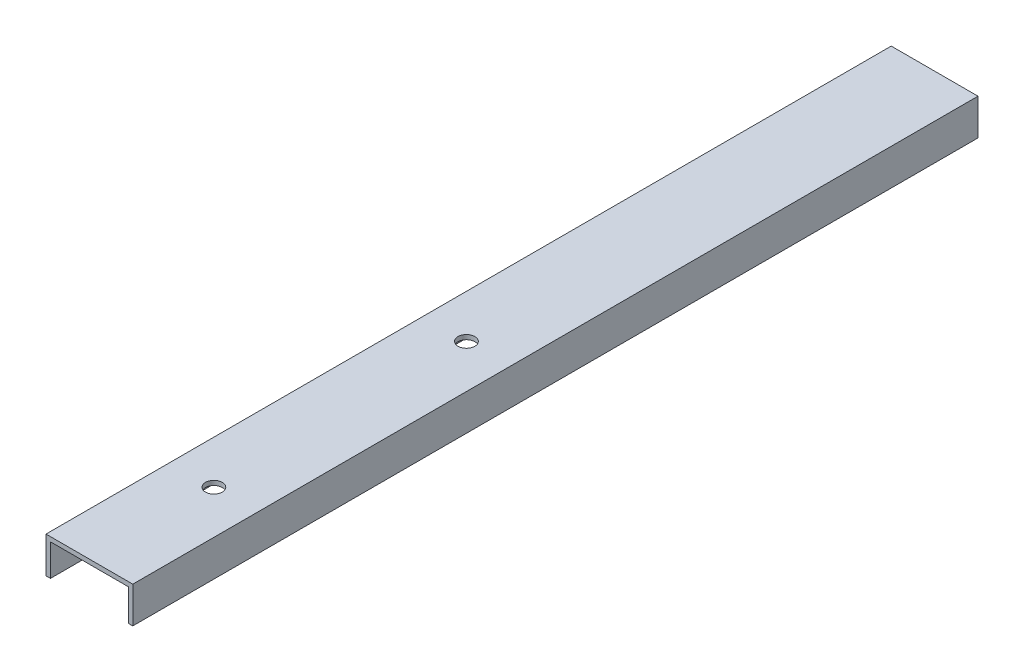
from build123d import *

# Parameters (mm, degrees)
BOSS_EXTRUDE1_DEPTH          = 239.7125
SKETCH3_R                    = 2.3876
RECOGNIZER_MOUNT_HOLES_DEPTH = 11.2616


with BuildPart() as part:
    # Sketch1 → Boss-Extrude1 (new body)
    with BuildSketch(Plane.XY):
        Polygon((0, 0), (0, 10.2616), (24.6126, 10.2616), (24.6126, 0), (23.3426, 0), (23.3426, 8.9916), (1.27, 8.9916), (1.27, 0), align=None)
    extrude(amount=BOSS_EXTRUDE1_DEPTH)

    # Sketch3 → Recognizer mount holes (cut, through all)
    with BuildSketch(Plane(origin=(0, 10.2616, 0), x_dir=(1, 0, 0), z_dir=(0, 1, 0))):
        with Locations((12.3063, -204.4065)):
            Circle(SKETCH3_R)
        with Locations((12.3063, -132.7785)):
            Circle(SKETCH3_R)
    extrude(amount=-RECOGNIZER_MOUNT_HOLES_DEPTH, mode=Mode.SUBTRACT)


solid = part.part
